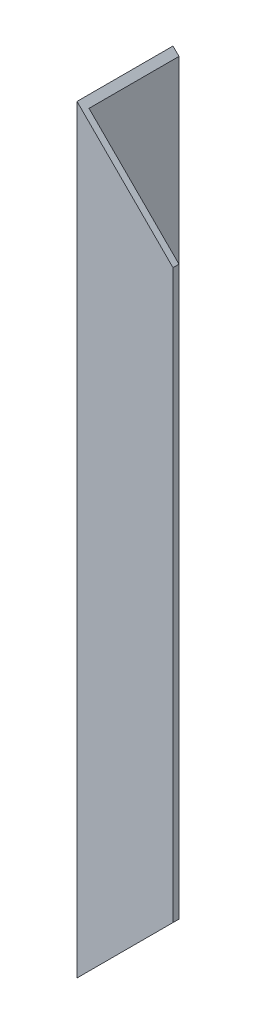
from build123d import *

# Parameters (mm, degrees)
BOSS_EXTRUDE2_DEPTH = 200.914
CUT_EXTRUDE1_DEPTH  = 26.4
CUT_EXTRUDE2_DEPTH  = 26.4


with BuildPart() as part:
    # Sketch2 → Boss-Extrude2 (new body)
    with BuildSketch(Plane(origin=(0, 0, 0), x_dir=(1, 0, 0), z_dir=(0, 1, 0))):
        Polygon((0, 0), (0, 25.4), (1.5875, 25.4), (1.5875, 1.5875), (25.4, 1.5875), (25.4, 0), align=None)
    extrude(amount=BOSS_EXTRUDE2_DEPTH)

    # Sketch4 → Cut-Extrude1 (cut, through all)
    with BuildSketch(Plane.XY):
        Polygon((0, 200.914), (25.4, 175.514), (25.4, 200.914), align=None)
    extrude(amount=-CUT_EXTRUDE1_DEPTH, mode=Mode.SUBTRACT)

    # Sketch5 → Cut-Extrude2 (cut, through all)
    with BuildSketch(Plane.XY):
        Polygon((0, 0), (25.4, 25.4), (25.4, 0), align=None)
    extrude(amount=-CUT_EXTRUDE2_DEPTH, mode=Mode.SUBTRACT)


solid = part.part
